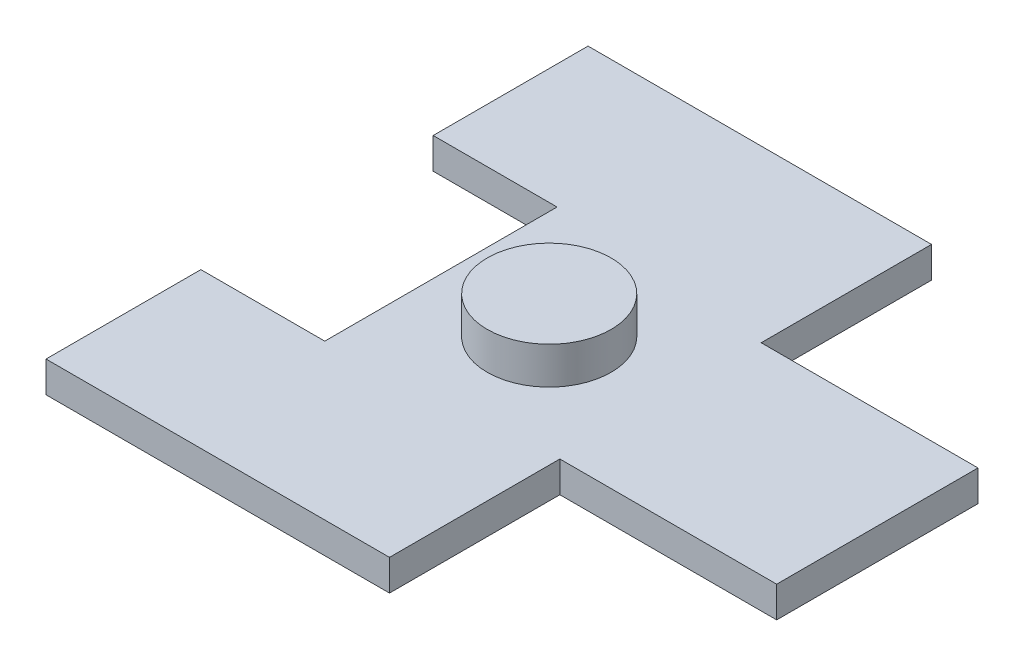
from build123d import *

# Parameters (mm, degrees)
BOSS_EXTRUDE1_DEPTH = 2
SKETCH2_R           = 4
BOSS_EXTRUDE2_DEPTH = 2.4


with BuildPart() as part:
    # Sketch1 → Boss-Extrude1 (new body)
    with BuildSketch(Plane(origin=(0, 0, 0), x_dir=(1, 0, 0), z_dir=(0, 1, 0))):
        Polygon((0.624790047, 6.5), (0.624790047, 17.5), (-9.416796267, 17.5), (-21.555209953, 17.5), (-21.555209953, 7.5), (-13.555209953, 7.5), (-13.555209953, -7.5), (-21.555209953, -7.5), (-21.555209953, -17.5), (-9.416796267, -17.5), (0.624790047, -17.5), (0.624790047, -6.5), (14.624790047, -6.5), (14.624790047, 6.5), align=None)
    extrude(amount=BOSS_EXTRUDE1_DEPTH)

    # Sketch2 → Boss-Extrude2 (add)
    with BuildSketch(Plane(origin=(0, 2, 0), x_dir=(1, 0, 0), z_dir=(0, 1, 0))):
        with Locations((-6.563909953, 0)):
            Circle(SKETCH2_R)
    extrude(amount=BOSS_EXTRUDE2_DEPTH)


solid = part.part
